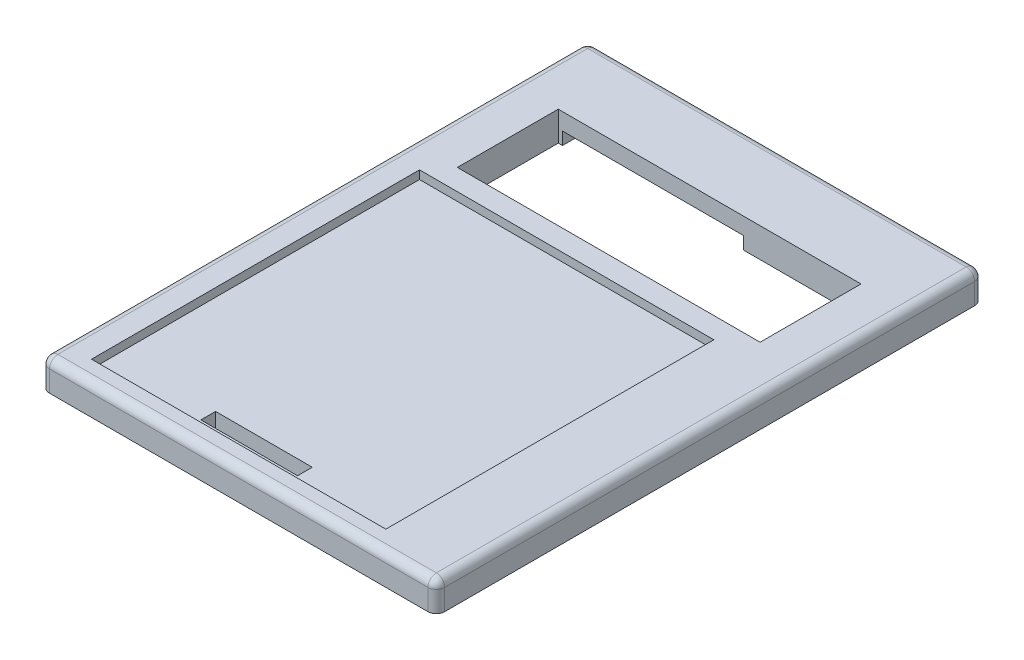
from build123d import *

# Parameters (mm, degrees)
SKETCH1_W           = 94
SKETCH1_H           = 130
BOSS_EXTRUDE1_DEPTH = 7
SKETCH2_W           = 72
SKETCH2_H           = 24
CUT_EXTRUDE1_DEPTH  = 8
SKETCH3_W           = 6
SKETCH3_H           = 18
CUT_EXTRUDE2_DEPTH  = 3.5
SKETCH4_W           = 43
SKETCH4_H           = 7.5
CUT_EXTRUDE3_DEPTH  = 3
SKETCH5_W           = 70
SKETCH5_H           = 78
CUT_EXTRUDE4_DEPTH  = 2
SKETCH6_W           = 23
SKETCH6_H           = 3.5
CUT_EXTRUDE5_DEPTH  = 6
FILLET1_R           = 2


with BuildPart() as part:
    # Sketch1 → Boss-Extrude1 (new body)
    with BuildSketch(Plane(origin=(0, 0, 0), x_dir=(1, 0, 0), z_dir=(0, 1, 0))):
        with Locations((47, 65)):
            Rectangle(SKETCH1_W, SKETCH1_H)
    extrude(amount=BOSS_EXTRUDE1_DEPTH)

    # Sketch2 → Cut-Extrude1 (cut, through all)
    with BuildSketch(Plane(origin=(0, 7, 0), x_dir=(1, 0, 0), z_dir=(0, 1, 0))):
        with Locations((47, 100)):
            Rectangle(SKETCH2_W, SKETCH2_H)
    extrude(amount=-CUT_EXTRUDE1_DEPTH, mode=Mode.SUBTRACT)

    # Sketch3 → Cut-Extrude2 (cut)
    with BuildSketch(Plane.XZ):
        with Locations((86, -100)):
            Rectangle(SKETCH3_W, SKETCH3_H)
    extrude(amount=-CUT_EXTRUDE2_DEPTH, mode=Mode.SUBTRACT)

    # Sketch4 → Cut-Extrude3 (cut)
    with BuildSketch(Plane.XZ):
        with Locations((33.5, -115.75)):
            Rectangle(SKETCH4_W, SKETCH4_H)
    extrude(amount=-CUT_EXTRUDE3_DEPTH, mode=Mode.SUBTRACT)

    # Sketch5 → Cut-Extrude4 (cut)
    with BuildSketch(Plane(origin=(0, 7, 0), x_dir=(1, 0, 0), z_dir=(0, 1, 0))):
        with Locations((42, 44)):
            Rectangle(SKETCH5_W, SKETCH5_H)
    extrude(amount=-CUT_EXTRUDE4_DEPTH, mode=Mode.SUBTRACT)

    # Sketch6 → Cut-Extrude5 (cut, through all)
    with BuildSketch(Plane(origin=(0, 5, 0), x_dir=(1, 0, 0), z_dir=(0, 1, 0))):
        with Locations((42, 9.25)):
            Rectangle(SKETCH6_W, SKETCH6_H)
    extrude(amount=-CUT_EXTRUDE5_DEPTH, mode=Mode.SUBTRACT)

    # Fillet1
    fillet1_edges = [part.edges().sort_by_distance(p)[0] for p in [
        (94, 7, -65),
        (47, 7, -130),
        (0, 7, -65),
        (0, 3.5, -130),
        (94, 3.5, -130),
        (94, 3.5, 0),
        (0, 3.5, 0),
        (47, 7, 0),
    ]]
    fillet(fillet1_edges, radius=FILLET1_R)


solid = part.part
